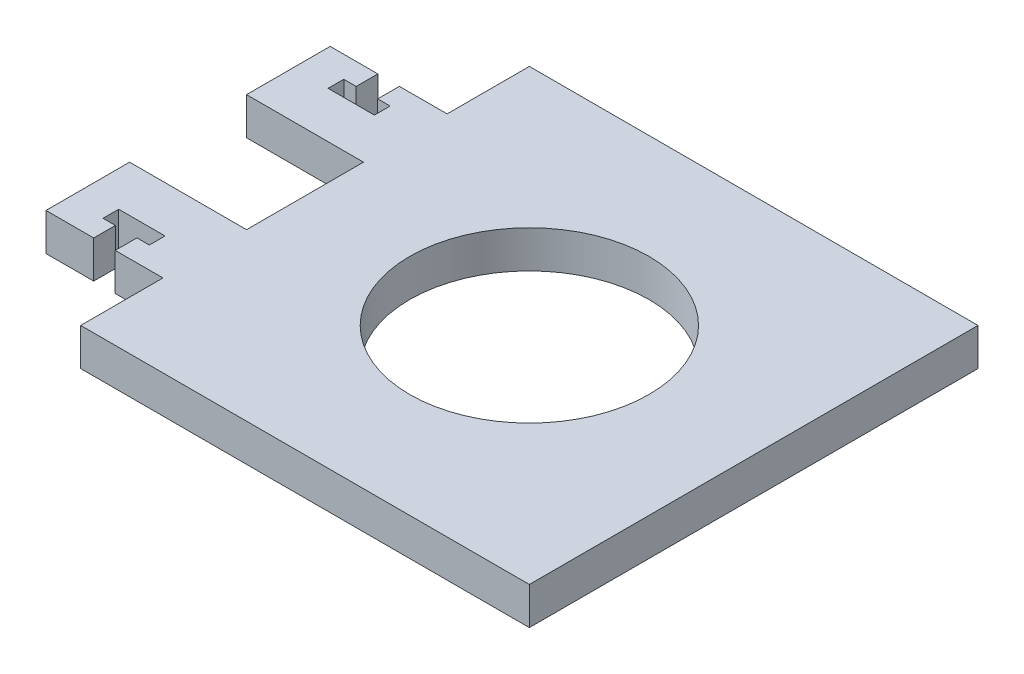
from build123d import *

# Parameters (mm, degrees)
SKETCH1_R           = 20.32
BOSS_EXTRUDE1_DEPTH = 6.35


with BuildPart() as part:
    # Sketch1 → Boss-Extrude1 (new body)
    with BuildSketch(Plane(origin=(0, 0, 0), x_dir=(1, 0, 0), z_dir=(0, 1, 0))):
        Polygon((-38.1, -38.1), (38.1, -38.1), (38.1, 38.1), (-38.1, 38.1), (-38.1, 24.13), (-46.2026, 24.13), (-46.2026, 20.447), (-44.0944, 20.447), (-44.0944, 17.78), (-51.9684, 17.78), (-51.9684, 20.447), (-49.8602, 20.447), (-49.8602, 24.13), (-57.9628, 24.13), (-57.9628, 9.9314), (-38.1, 9.9314), (-38.1, -9.9314), (-57.9628, -9.9314), (-57.9628, -24.13), (-49.8602, -24.13), (-49.8602, -20.447), (-51.9684, -20.447), (-51.9684, -17.78), (-44.0944, -17.78), (-44.0944, -20.447), (-46.2026, -20.447), (-46.2026, -24.13), (-38.1, -24.13), align=None)
        Circle(SKETCH1_R, mode=Mode.SUBTRACT)
    extrude(amount=-BOSS_EXTRUDE1_DEPTH)


solid = part.part
